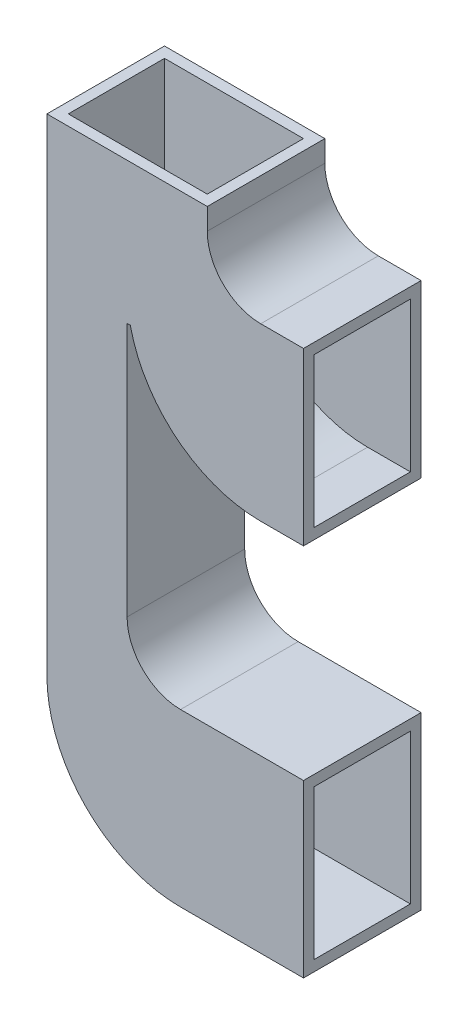
from build123d import *

# Parameters (mm, degrees)
RESSALTO_EXTRUS_O1_DEPTH = 11
CASCA2_T                 = -1


with BuildPart() as part:
    # Esboço1 → Ressalto-extrusão1 (new body)
    with BuildSketch(Plane.XY):
        with BuildLine():
            Line((0, 45.5), (0, 0))
            ThreePointArc((0, 0), (3.661165235, -8.838834765), (12.5, -12.5))
            Line((12.5, -12.5), (24, -12.5))
            Line((24, -12.5), (24, 3.5))
            Line((24, 3.5), (12.5, 3.5))
            ThreePointArc((12.5, 3.5), (8.964466094, 4.964466094), (7.5, 8.5))
            Line((7.5, 8.5), (7.5, 32.277868482))
            Line((7.5, 32.277868482), (7.8, 32.277868482))
            ThreePointArc((7.8, 32.277868482), (12.182604141, 25.246112468), (20, 22.5))
            Line((20, 22.5), (24, 22.5))
            Line((24, 22.5), (24, 38.5))
            Line((24, 38.5), (20, 38.5))
            ThreePointArc((20, 38.5), (16.464466094, 39.964466094), (15, 43.5))
            Line((15, 43.5), (15, 45.5))
            Line((15, 45.5), (0, 45.5))
        make_face()
    extrude(amount=RESSALTO_EXTRUS_O1_DEPTH)

    # Casca2
    casca2_openings = [part.faces().sort_by_distance(p)[0] for p in [
        (24, 30.5, 5.5),
        (24, -4.5, 5.5),
        (7.5, 45.5, 5.5),
    ]]
    offset(amount=CASCA2_T, openings=casca2_openings, kind=Kind.INTERSECTION)


solid = part.part
